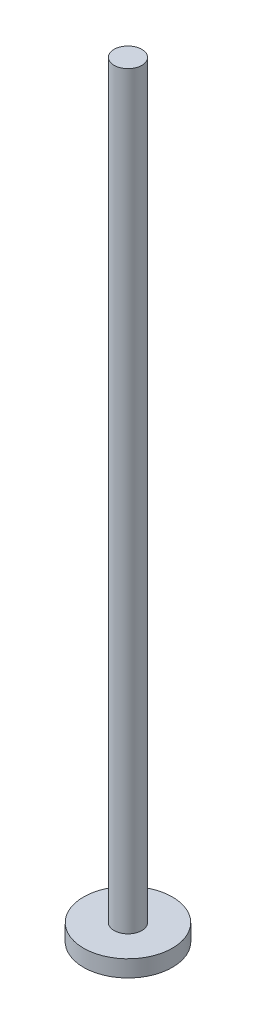
from build123d import *

# Parameters (mm, degrees)
SKETCH_1_R      = 8
EXTRUDE_1_DEPTH = 3
SKETCH_2_R      = 2.5
EXTRUDE_2_DEPTH = 135


with BuildPart() as part:
    # 草图1 → 凸台-拉伸1 (new body)
    with BuildSketch(Plane(origin=(0, 0, 0), x_dir=(1, 0, 0), z_dir=(0, 1, 0))):
        Circle(SKETCH_1_R)
    extrude(amount=EXTRUDE_1_DEPTH)

    # 草图2 → 凸台-拉伸2 (add)
    with BuildSketch(Plane(origin=(0, 3, 0), x_dir=(1, 0, 0), z_dir=(0, 1, 0))):
        Circle(SKETCH_2_R)
    extrude(amount=EXTRUDE_2_DEPTH)


solid = part.part
